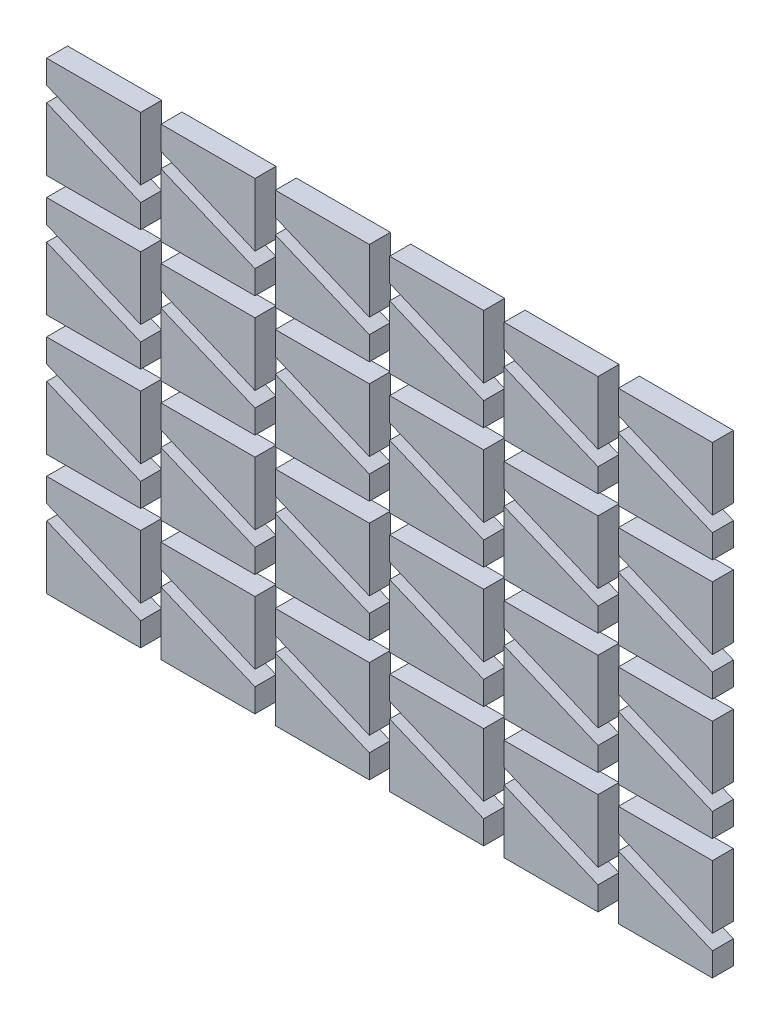
from build123d import *

# Parameters (mm, degrees)
BOSS_EXTRUDE1_DEPTH = 1.05
CIRPATTERN1_COUNT   = 2
LPATTERN1_COUNT     = 4
LPATTERN1_PITCH     = 12.065
LPATTERN1_2_COUNT   = 6
LPATTERN1_2_PITCH   = 11.43


with BuildPart() as part:
    # Sketch1 → Boss-Extrude1 (new, symmetric)
    with BuildSketch(Plane.XY):
        Polygon((-4.699, -5.08), (4.699, -5.08), (4.699, -2.7305), (-4.699, 1.2192), align=None)
    extrude(amount=BOSS_EXTRUDE1_DEPTH, both=True)


with BuildPart() as cirpattern1_1:
    # CirPattern1: pattern copy
    add(part.part.rotate(Axis((0, 0, 1.155), (0, 0, -1)), 1 * 360 / CIRPATTERN1_COUNT))


with BuildPart() as lpattern1_1:
    # LPattern1: pattern copy
    add(cirpattern1_1.part.moved(Location(Vector(0, 1, 0) * (1 * LPATTERN1_PITCH))))


with BuildPart() as lpattern1_2:
    # LPattern1: pattern copy
    add(cirpattern1_1.part.moved(Location(Vector(0, 1, 0) * (2 * LPATTERN1_PITCH))))


with BuildPart() as lpattern1_3:
    # LPattern1: pattern copy
    add(cirpattern1_1.part.moved(Location(Vector(0, 1, 0) * (3 * LPATTERN1_PITCH))))


with BuildPart() as lpattern1_4:
    # LPattern1: pattern copy
    add(part.part.moved(Location(Vector(0, 1, 0) * (1 * LPATTERN1_PITCH))))


with BuildPart() as lpattern1_5:
    # LPattern1: pattern copy
    add(part.part.moved(Location(Vector(0, 1, 0) * (2 * LPATTERN1_PITCH))))


with BuildPart() as lpattern1_6:
    # LPattern1: pattern copy
    add(part.part.moved(Location(Vector(0, 1, 0) * (3 * LPATTERN1_PITCH))))


with BuildPart() as lpattern1_2_1:
    # LPattern1 2: pattern copy
    add(cirpattern1_1.part.moved(Location(Vector(1, 0, 0) * (1 * LPATTERN1_2_PITCH))))


with BuildPart() as lpattern1_2_2:
    # LPattern1 2: pattern copy
    add(cirpattern1_1.part.moved(Location(Vector(1, 0, 0) * (2 * LPATTERN1_2_PITCH))))


with BuildPart() as lpattern1_2_3:
    # LPattern1 2: pattern copy
    add(cirpattern1_1.part.moved(Location(Vector(1, 0, 0) * (3 * LPATTERN1_2_PITCH))))


with BuildPart() as lpattern1_2_4:
    # LPattern1 2: pattern copy
    add(cirpattern1_1.part.moved(Location(Vector(1, 0, 0) * (4 * LPATTERN1_2_PITCH))))


with BuildPart() as lpattern1_2_5:
    # LPattern1 2: pattern copy
    add(cirpattern1_1.part.moved(Location(Vector(1, 0, 0) * (5 * LPATTERN1_2_PITCH))))


with BuildPart() as lpattern1_2_6:
    # LPattern1 2: pattern copy
    add(part.part.moved(Location(Vector(1, 0, 0) * (1 * LPATTERN1_2_PITCH))))


with BuildPart() as lpattern1_2_7:
    # LPattern1 2: pattern copy
    add(part.part.moved(Location(Vector(1, 0, 0) * (2 * LPATTERN1_2_PITCH))))


with BuildPart() as lpattern1_2_8:
    # LPattern1 2: pattern copy
    add(part.part.moved(Location(Vector(1, 0, 0) * (3 * LPATTERN1_2_PITCH))))


with BuildPart() as lpattern1_2_9:
    # LPattern1 2: pattern copy
    add(part.part.moved(Location(Vector(1, 0, 0) * (4 * LPATTERN1_2_PITCH))))


with BuildPart() as lpattern1_2_10:
    # LPattern1 2: pattern copy
    add(part.part.moved(Location(Vector(1, 0, 0) * (5 * LPATTERN1_2_PITCH))))


with BuildPart() as lpattern1_2_11:
    # LPattern1 2: pattern copy
    add(lpattern1_1.part.moved(Location(Vector(1, 0, 0) * (1 * LPATTERN1_2_PITCH))))


with BuildPart() as lpattern1_2_12:
    # LPattern1 2: pattern copy
    add(lpattern1_1.part.moved(Location(Vector(1, 0, 0) * (2 * LPATTERN1_2_PITCH))))


with BuildPart() as lpattern1_2_13:
    # LPattern1 2: pattern copy
    add(lpattern1_1.part.moved(Location(Vector(1, 0, 0) * (3 * LPATTERN1_2_PITCH))))


with BuildPart() as lpattern1_2_14:
    # LPattern1 2: pattern copy
    add(lpattern1_1.part.moved(Location(Vector(1, 0, 0) * (4 * LPATTERN1_2_PITCH))))


with BuildPart() as lpattern1_2_15:
    # LPattern1 2: pattern copy
    add(lpattern1_1.part.moved(Location(Vector(1, 0, 0) * (5 * LPATTERN1_2_PITCH))))


with BuildPart() as lpattern1_2_16:
    # LPattern1 2: pattern copy
    add(lpattern1_2.part.moved(Location(Vector(1, 0, 0) * (1 * LPATTERN1_2_PITCH))))


with BuildPart() as lpattern1_2_17:
    # LPattern1 2: pattern copy
    add(lpattern1_2.part.moved(Location(Vector(1, 0, 0) * (2 * LPATTERN1_2_PITCH))))


with BuildPart() as lpattern1_2_18:
    # LPattern1 2: pattern copy
    add(lpattern1_2.part.moved(Location(Vector(1, 0, 0) * (3 * LPATTERN1_2_PITCH))))


with BuildPart() as lpattern1_2_19:
    # LPattern1 2: pattern copy
    add(lpattern1_2.part.moved(Location(Vector(1, 0, 0) * (4 * LPATTERN1_2_PITCH))))


with BuildPart() as lpattern1_2_20:
    # LPattern1 2: pattern copy
    add(lpattern1_2.part.moved(Location(Vector(1, 0, 0) * (5 * LPATTERN1_2_PITCH))))


with BuildPart() as lpattern1_2_21:
    # LPattern1 2: pattern copy
    add(lpattern1_3.part.moved(Location(Vector(1, 0, 0) * (1 * LPATTERN1_2_PITCH))))


with BuildPart() as lpattern1_2_22:
    # LPattern1 2: pattern copy
    add(lpattern1_3.part.moved(Location(Vector(1, 0, 0) * (2 * LPATTERN1_2_PITCH))))


with BuildPart() as lpattern1_2_23:
    # LPattern1 2: pattern copy
    add(lpattern1_3.part.moved(Location(Vector(1, 0, 0) * (3 * LPATTERN1_2_PITCH))))


with BuildPart() as lpattern1_2_24:
    # LPattern1 2: pattern copy
    add(lpattern1_3.part.moved(Location(Vector(1, 0, 0) * (4 * LPATTERN1_2_PITCH))))


with BuildPart() as lpattern1_2_25:
    # LPattern1 2: pattern copy
    add(lpattern1_3.part.moved(Location(Vector(1, 0, 0) * (5 * LPATTERN1_2_PITCH))))


with BuildPart() as lpattern1_2_26:
    # LPattern1 2: pattern copy
    add(lpattern1_4.part.moved(Location(Vector(1, 0, 0) * (1 * LPATTERN1_2_PITCH))))


with BuildPart() as lpattern1_2_27:
    # LPattern1 2: pattern copy
    add(lpattern1_4.part.moved(Location(Vector(1, 0, 0) * (2 * LPATTERN1_2_PITCH))))


with BuildPart() as lpattern1_2_28:
    # LPattern1 2: pattern copy
    add(lpattern1_4.part.moved(Location(Vector(1, 0, 0) * (3 * LPATTERN1_2_PITCH))))


with BuildPart() as lpattern1_2_29:
    # LPattern1 2: pattern copy
    add(lpattern1_4.part.moved(Location(Vector(1, 0, 0) * (4 * LPATTERN1_2_PITCH))))


with BuildPart() as lpattern1_2_30:
    # LPattern1 2: pattern copy
    add(lpattern1_4.part.moved(Location(Vector(1, 0, 0) * (5 * LPATTERN1_2_PITCH))))


with BuildPart() as lpattern1_2_31:
    # LPattern1 2: pattern copy
    add(lpattern1_5.part.moved(Location(Vector(1, 0, 0) * (1 * LPATTERN1_2_PITCH))))


with BuildPart() as lpattern1_2_32:
    # LPattern1 2: pattern copy
    add(lpattern1_5.part.moved(Location(Vector(1, 0, 0) * (2 * LPATTERN1_2_PITCH))))


with BuildPart() as lpattern1_2_33:
    # LPattern1 2: pattern copy
    add(lpattern1_5.part.moved(Location(Vector(1, 0, 0) * (3 * LPATTERN1_2_PITCH))))


with BuildPart() as lpattern1_2_34:
    # LPattern1 2: pattern copy
    add(lpattern1_5.part.moved(Location(Vector(1, 0, 0) * (4 * LPATTERN1_2_PITCH))))


with BuildPart() as lpattern1_2_35:
    # LPattern1 2: pattern copy
    add(lpattern1_5.part.moved(Location(Vector(1, 0, 0) * (5 * LPATTERN1_2_PITCH))))


with BuildPart() as lpattern1_2_36:
    # LPattern1 2: pattern copy
    add(lpattern1_6.part.moved(Location(Vector(1, 0, 0) * (1 * LPATTERN1_2_PITCH))))


with BuildPart() as lpattern1_2_37:
    # LPattern1 2: pattern copy
    add(lpattern1_6.part.moved(Location(Vector(1, 0, 0) * (2 * LPATTERN1_2_PITCH))))


with BuildPart() as lpattern1_2_38:
    # LPattern1 2: pattern copy
    add(lpattern1_6.part.moved(Location(Vector(1, 0, 0) * (3 * LPATTERN1_2_PITCH))))


with BuildPart() as lpattern1_2_39:
    # LPattern1 2: pattern copy
    add(lpattern1_6.part.moved(Location(Vector(1, 0, 0) * (4 * LPATTERN1_2_PITCH))))


with BuildPart() as lpattern1_2_40:
    # LPattern1 2: pattern copy
    add(lpattern1_6.part.moved(Location(Vector(1, 0, 0) * (5 * LPATTERN1_2_PITCH))))


solid = Compound([part.part, cirpattern1_1.part, lpattern1_1.part, lpattern1_2.part, lpattern1_3.part, lpattern1_4.part, lpattern1_5.part, lpattern1_6.part, lpattern1_2_1.part, lpattern1_2_2.part, lpattern1_2_3.part, lpattern1_2_4.part, lpattern1_2_5.part, lpattern1_2_6.part, lpattern1_2_7.part, lpattern1_2_8.part, lpattern1_2_9.part, lpattern1_2_10.part, lpattern1_2_11.part, lpattern1_2_12.part, lpattern1_2_13.part, lpattern1_2_14.part, lpattern1_2_15.part, lpattern1_2_16.part, lpattern1_2_17.part, lpattern1_2_18.part, lpattern1_2_19.part, lpattern1_2_20.part, lpattern1_2_21.part, lpattern1_2_22.part, lpattern1_2_23.part, lpattern1_2_24.part, lpattern1_2_25.part, lpattern1_2_26.part, lpattern1_2_27.part, lpattern1_2_28.part, lpattern1_2_29.part, lpattern1_2_30.part, lpattern1_2_31.part, lpattern1_2_32.part, lpattern1_2_33.part, lpattern1_2_34.part, lpattern1_2_35.part, lpattern1_2_36.part, lpattern1_2_37.part, lpattern1_2_38.part, lpattern1_2_39.part, lpattern1_2_40.part])
